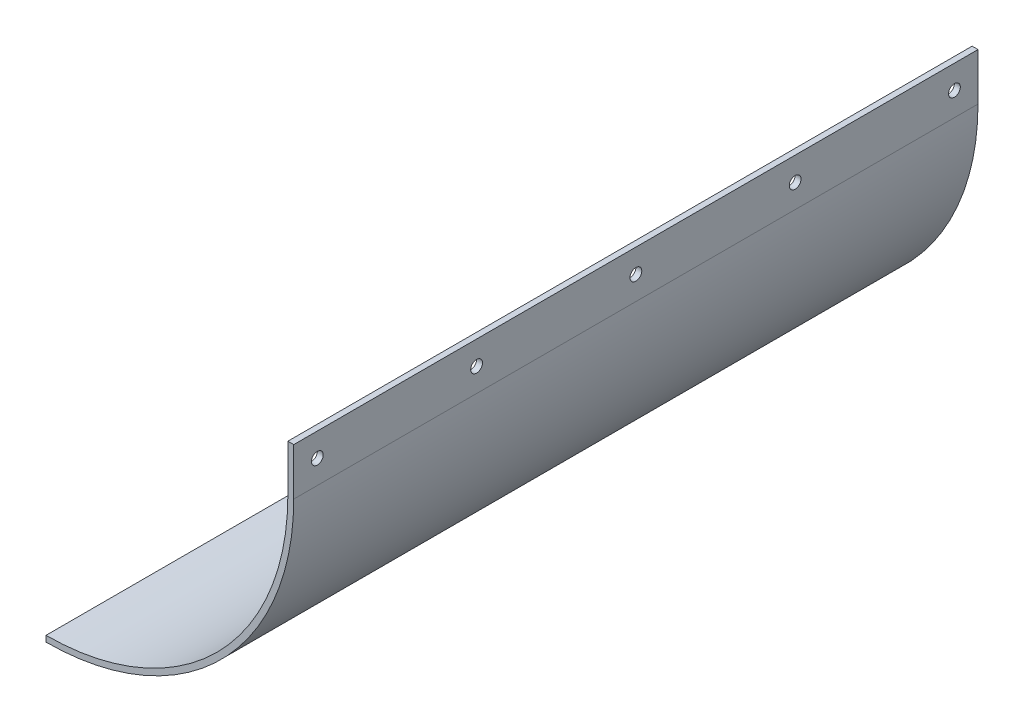
from build123d import *

# Parameters (mm, degrees)
BOSS_EXTRUDE1_DEPTH = 184.15
SKETCH2_R           = 3.175
CUT_EXTRUDE1_DEPTH  = 381


with BuildPart() as part:
    # Sketch1 → Boss-Extrude1 (new body, symmetric)
    with BuildSketch(Plane.XY):
        with BuildLine():
            Line((0, -133.35), (0, -130.175))
            ThreePointArc((0, -130.175), (92.047625241, -92.047625241), (130.175, 0))
            Line((130.175, 0), (130.175, 25.4))
            Line((130.175, 25.4), (133.35, 25.4))
            Line((133.35, 25.4), (133.35, 0))
            ThreePointArc((133.35, 0), (94.292689271, -94.292689271), (0, -133.35))
        make_face()
    extrude(amount=BOSS_EXTRUDE1_DEPTH, both=True)

    # Sketch2 → Cut-Extrude1 (cut)
    with BuildSketch(Plane(origin=(133.35, 0, 0), x_dir=(0, 0, -1), z_dir=(1, 0, 0))):
        with Locations((0, 12.7)):
            Circle(SKETCH2_R)
        with Locations((85.725, 12.7)):
            Circle(SKETCH2_R)
        with Locations((-85.725, 12.7)):
            Circle(SKETCH2_R)
        with Locations((-171.45, 12.7)):
            Circle(SKETCH2_R)
        with Locations((171.45, 12.7)):
            Circle(SKETCH2_R)
    extrude(amount=-CUT_EXTRUDE1_DEPTH, mode=Mode.SUBTRACT)


solid = part.part
